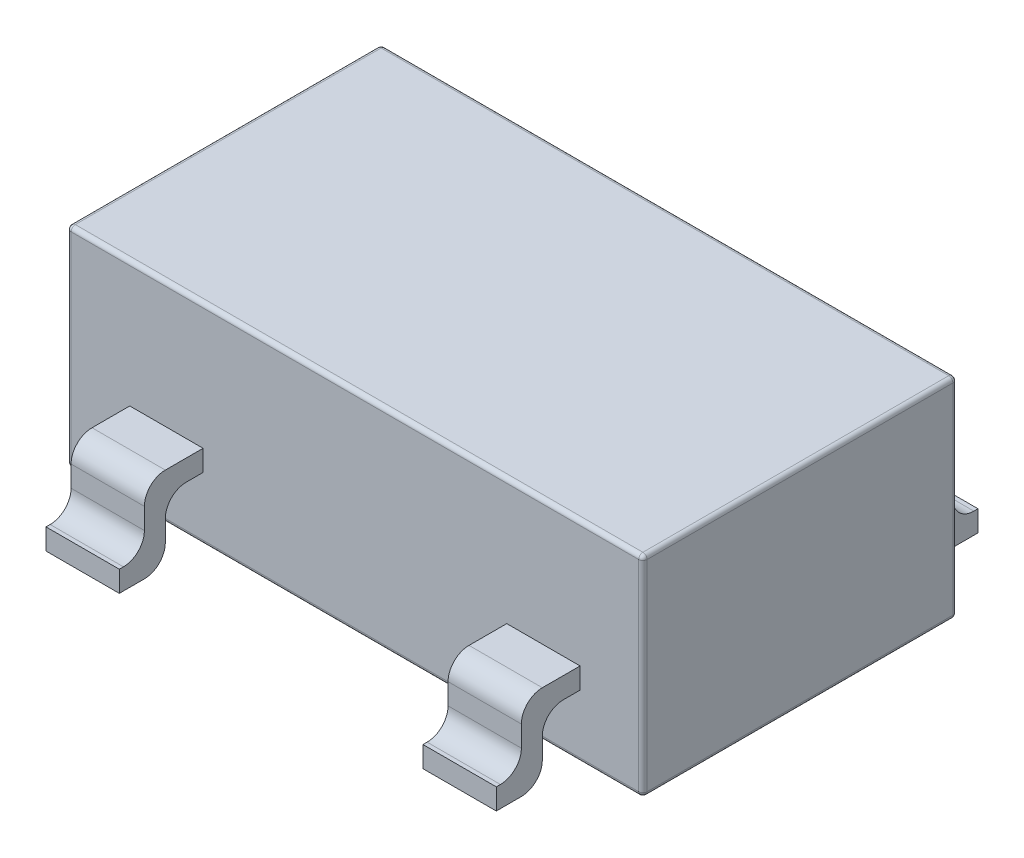
from build123d import *

# Parameters (mm, degrees)
SKETCH1_W           = 2.75
SKETCH1_H           = 1.5
BOSS_EXTRUDE1_DEPTH = 1
SKETCH2_W           = 0.35
SKETCH2_H           = 0.4
BOSS_EXTRUDE2_DEPTH = 0.4
CUT_EXTRUDE1_DEPTH  = 3.45
FILLET1_R           = 0.02


with BuildPart() as part:
    # Sketch1 → Boss-Extrude1 (new body)
    with BuildSketch(Plane(origin=(0, 0, 0), x_dir=(1, 0, 0), z_dir=(0, 1, 0))):
        Rectangle(SKETCH1_W, SKETCH1_H)
    extrude(amount=BOSS_EXTRUDE1_DEPTH)

    # Sketch2 → Boss-Extrude2 (add)
    with BuildSketch(Plane(origin=(0, 0, 0), x_dir=(1, 0, 0), z_dir=(0, 1, 0))):
        with Locations((-0.9, -0.95)):
            Rectangle(SKETCH2_W, SKETCH2_H)
        with Locations((0.9, -0.95)):
            Rectangle(SKETCH2_W, SKETCH2_H)
        with Locations((0.9, 0.95)):
            Rectangle(SKETCH2_W, SKETCH2_H)
        with Locations((-0.9, 0.95)):
            Rectangle(SKETCH2_W, SKETCH2_H)
        with Locations((0.01189142, 0.95)):
            Rectangle(SKETCH2_W, SKETCH2_H)
    extrude(amount=BOSS_EXTRUDE2_DEPTH)

    # Sketch3 → Cut-Extrude1 (cut, through all)
    with BuildSketch(Plane(origin=(1.075, 0, 0), x_dir=(0, 0, -1), z_dir=(1, 0, 0))):
        with BuildLine():
            Line((1.15, 0), (1.03024595, 0))
            Line((1.03024595, 0), (0.75, 0))
            Line((0.75, 0), (-0.75, 0))
            Line((-0.75, 0), (-0.75, 0.3))
            Line((-0.75, 0.3), (-0.83024595, 0.3))
            ThreePointArc((-0.83024595, 0.3), (-0.900956628, 0.270710678), (-0.93024595, 0.2))
            Line((-0.93024595, 0.2), (-0.93024595, 0.1))
            ThreePointArc((-0.93024595, 0.1), (-0.959535272, 0.029289322), (-1.03024595, 0))
            Line((-1.03024595, 0), (-1.15, 0))
            Line((-1.15, 0), (-1.15, 0.1))
            Line((-1.15, 0.1), (-1.13024595, 0.1))
            ThreePointArc((-1.13024595, 0.1), (-1.059535272, 0.129289322), (-1.03024595, 0.2))
            Line((-1.03024595, 0.2), (-1.03024595, 0.3))
            ThreePointArc((-1.03024595, 0.3), (-1.000956628, 0.370710678), (-0.93024595, 0.4))
            Line((-0.93024595, 0.4), (-0.75, 0.4))
            Line((-0.75, 0.4), (-0.75, 0.722069531))
            Line((-0.75, 0.722069531), (-1.439294861, 0.722069531))
            Line((-1.439294861, 0.722069531), (-1.439294861, -0.262815914))
            Line((-1.439294861, -0.262815914), (1.563550176, -0.262815914))
            Line((1.563550176, -0.262815914), (1.563550176, 0.722069531))
            Line((1.563550176, 0.722069531), (0.75, 0.722069531))
            Line((0.75, 0.722069531), (0.75, 0.4))
            Line((0.75, 0.4), (0.93024595, 0.4))
            Line((0.93024595, 0.4), (1.15, 0.4))
            Line((1.15, 0.4), (1.15, 0.1))
            Line((1.15, 0.1), (1.15, 0))
        make_face()
        with BuildLine():
            Line((0.75, 0), (1.03024595, 0))
            ThreePointArc((1.03024595, 0), (0.959535272, 0.029289322), (0.93024595, 0.1))
            Line((0.93024595, 0.1), (0.93024595, 0.2))
            ThreePointArc((0.93024595, 0.2), (0.900956628, 0.270710678), (0.83024595, 0.3))
            Line((0.83024595, 0.3), (0.75, 0.3))
            Line((0.75, 0.3), (0.75, 0))
        make_face()
        with BuildLine():
            Line((1.13024595, 0.1), (1.15, 0.1))
            Line((1.15, 0.1), (1.15, 0.4))
            Line((1.15, 0.4), (0.93024595, 0.4))
            ThreePointArc((0.93024595, 0.4), (1.000956628, 0.370710678), (1.03024595, 0.3))
            Line((1.03024595, 0.3), (1.03024595, 0.2))
            ThreePointArc((1.03024595, 0.2), (1.059535272, 0.129289322), (1.13024595, 0.1))
        make_face()
    extrude(amount=-CUT_EXTRUDE1_DEPTH, mode=Mode.SUBTRACT)

    # Fillet1
    fillet1_edges = [part.edges().sort_by_distance(p)[0] for p in [
        (-1.375, 1, 0),
        (0, 1, 0.75),
        (1.375, 1, 0),
        (0, 0, 0.75),
        (-1.375, 0, 0),
        (0, 0, -0.75),
        (1.375, 0, 0),
        (0, 1, -0.75),
        (1.375, 0.5, 0.75),
        (-1.375, 0.5, 0.75),
        (-1.375, 0.5, -0.75),
        (1.375, 0.5, -0.75),
    ]]
    fillet(fillet1_edges, radius=FILLET1_R)


solid = part.part
